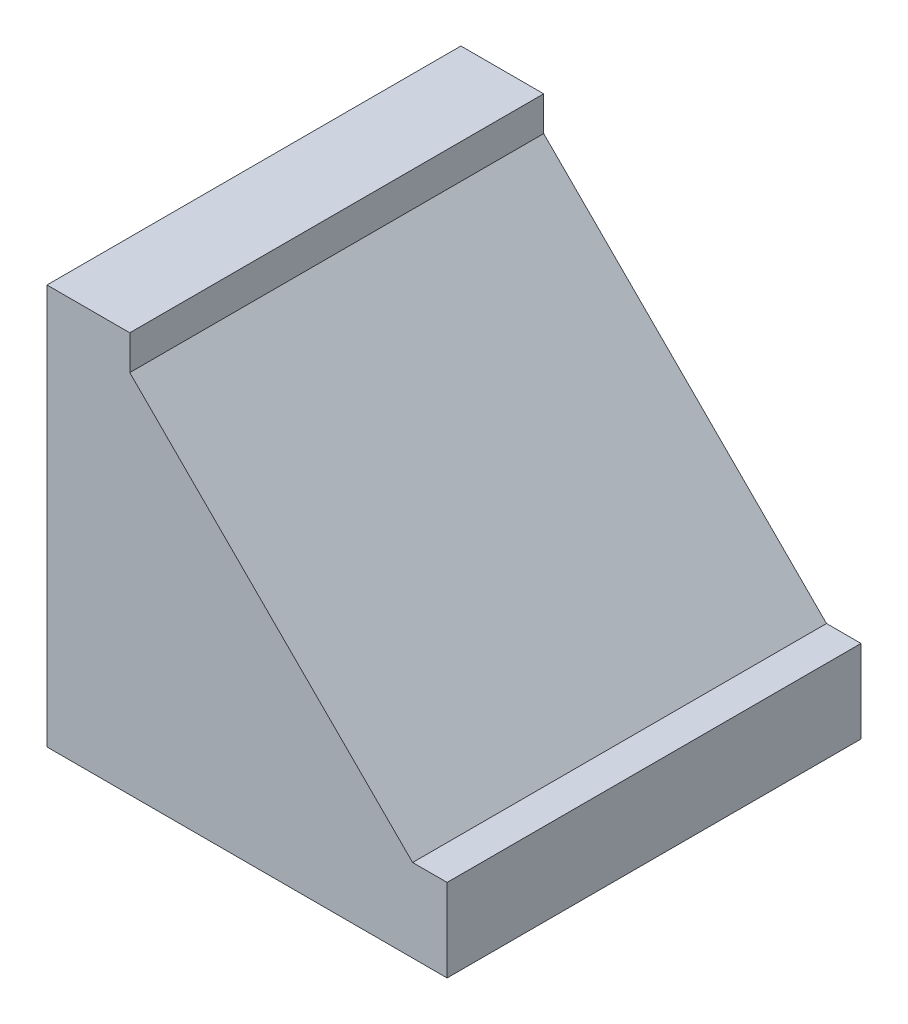
from build123d import *

# Parameters (mm, degrees)
EXTRUDE_1_DEPTH = 60


with BuildPart() as part:
    # 草图1 → 凸台-拉伸1 (new body)
    with BuildSketch(Plane.XY):
        Polygon((0, 58), (0, 0), (58, 0), (58, 12), (53, 12), (12, 53), (12, 58), align=None)
    extrude(amount=EXTRUDE_1_DEPTH)


solid = part.part
